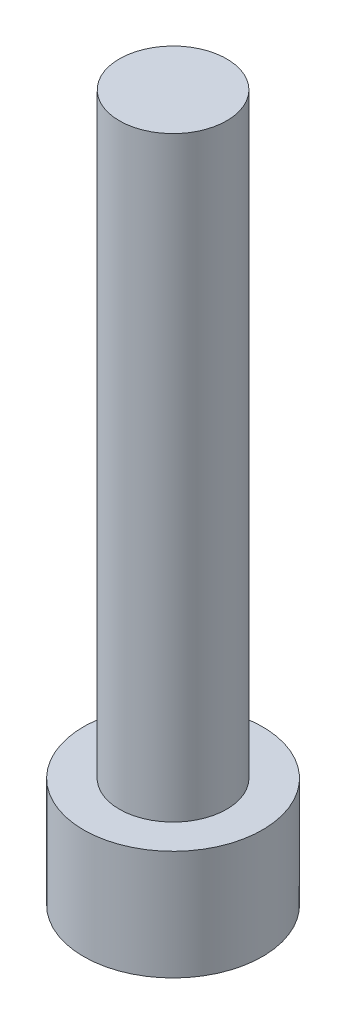
from build123d import *

# Parameters (mm, degrees)
SKETCH1_R           = 2.8575
BOSS_EXTRUDE1_DEPTH = 3.5052
CUT_EXTRUDE1_DEPTH  = 1.9558
SKETCH3_R           = 1.7145
BOSS_EXTRUDE2_DEPTH = 19.05


with BuildPart() as part:
    # Sketch1 → Boss-Extrude1 (new body)
    with BuildSketch(Plane(origin=(0, 0, 0), x_dir=(1, 0, 0), z_dir=(0, 1, 0))):
        Circle(SKETCH1_R)
    extrude(amount=BOSS_EXTRUDE1_DEPTH)

    # Sketch2 → Cut-Extrude1 (cut)
    with BuildSketch(Plane.XZ):
        Polygon((1.603951217, 0), (0.801975608, 1.3890625), (-0.801975608, 1.3890625), (-1.603951217, 0), (-0.801975608, -1.3890625), (0.801975608, -1.3890625), align=None)
    extrude(amount=-CUT_EXTRUDE1_DEPTH, mode=Mode.SUBTRACT)

    # Sketch3 → Boss-Extrude2 (add)
    with BuildSketch(Plane(origin=(0, 3.5052, 0), x_dir=(1, 0, 0), z_dir=(0, 1, 0))):
        Circle(SKETCH3_R)
    extrude(amount=BOSS_EXTRUDE2_DEPTH)


solid = part.part
